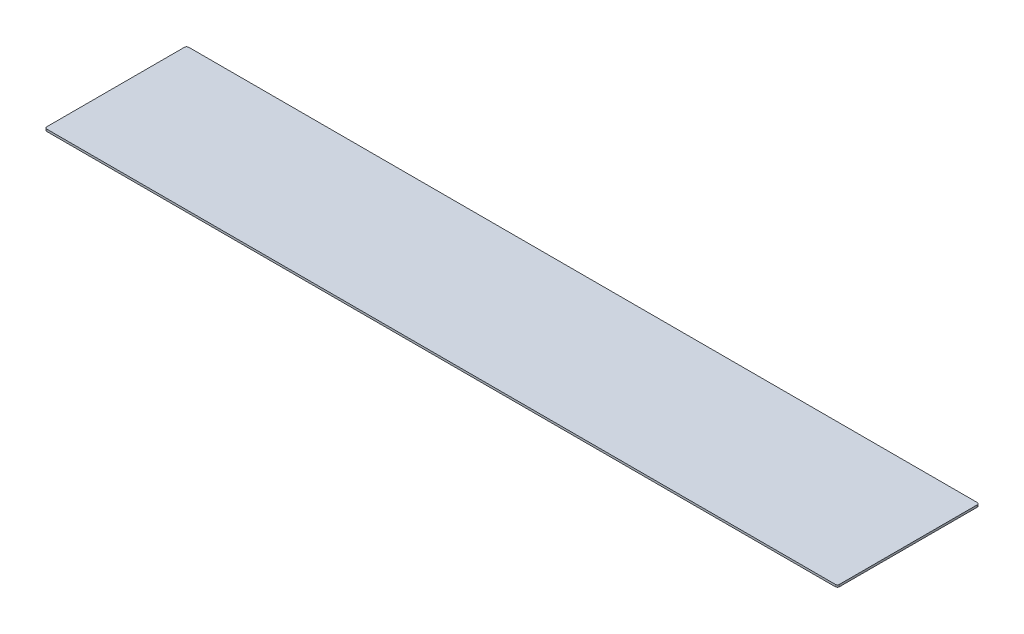
from build123d import *

# Parameters (mm, degrees)
BOSS_EXTRUDE1_DEPTH = 3.175


with BuildPart() as part:
    # Sketch1 → Boss-Extrude1 (new body)
    with BuildSketch(Plane(origin=(0, 0, 0), x_dir=(1, 0, 0), z_dir=(0, 1, 0))):
        with BuildLine():
            Line((-591.185, -106.3625), (591.185, -106.3625))
            ThreePointArc((591.185, -106.3625), (593.43006403, -105.43256403), (594.36, -103.1875))
            Line((594.36, -103.1875), (594.36, 103.1875))
            ThreePointArc((594.36, 103.1875), (593.43006403, 105.43256403), (591.185, 106.3625))
            Line((591.185, 106.3625), (-591.185, 106.3625))
            ThreePointArc((-591.185, 106.3625), (-593.43006403, 105.43256403), (-594.36, 103.1875))
            Line((-594.36, 103.1875), (-594.36, -103.1875))
            ThreePointArc((-594.36, -103.1875), (-593.43006403, -105.43256403), (-591.185, -106.3625))
        make_face()
    extrude(amount=BOSS_EXTRUDE1_DEPTH)


solid = part.part
